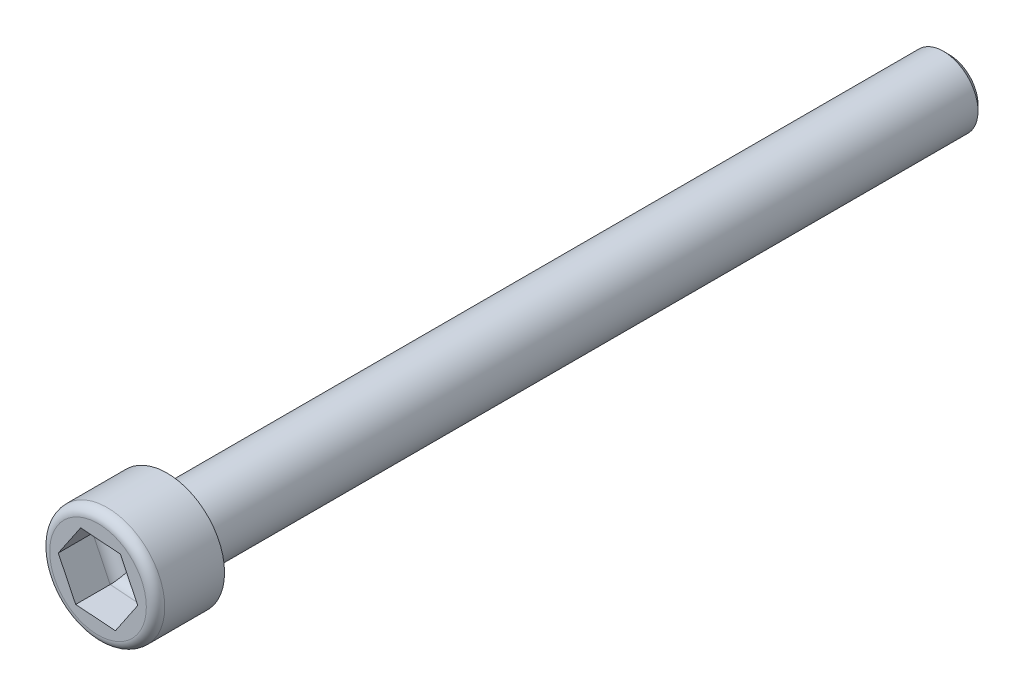
from build123d import *

# Parameters (mm, degrees)
SKETCH1_R           = 1.5
BOSS_EXTRUDE1_DEPTH = 34
SKETCH2_R           = 2.5
BOSS_EXTRUDE2_DEPTH = 3
CUT_EXTRUDE1_DEPTH  = 2
FILLET1_R           = 0.4
CHAMFER1_SIZE       = 0.25
FILLET2_R           = 0.5


with BuildPart() as part:
    # Sketch1 → Boss-Extrude1 (new body)
    with BuildSketch(Plane.XY):
        Circle(SKETCH1_R)
    extrude(amount=BOSS_EXTRUDE1_DEPTH)

    # Sketch2 → Boss-Extrude2 (add)
    with BuildSketch(Plane.XY.offset(34)):
        Circle(SKETCH2_R)
    extrude(amount=BOSS_EXTRUDE2_DEPTH)

    # Sketch3 → Cut-Extrude1 (cut)
    with BuildSketch(Plane.XY.offset(37)):
        Polygon((1.72759491, -0.124160484), (0.971323588, 1.434060838), (-0.756271322, 1.558221322), (-1.72759491, 0.124160484), (-0.971323588, -1.434060838), (0.756271322, -1.558221322), align=None)
    extrude(amount=-CUT_EXTRUDE1_DEPTH, mode=Mode.SUBTRACT)

    # Fillet1
    fillet1_edges = [part.edges().sort_by_distance(p)[0] for p in [
        (-2.5, 0, 37),
    ]]
    fillet(fillet1_edges, radius=FILLET1_R)

    # Chamfer1
    chamfer1_edges = [part.edges().sort_by_distance(p)[0] for p in [
        (-1.5, 0, 0),
    ]]
    chamfer(chamfer1_edges, length=CHAMFER1_SIZE)

    # Fillet2
    fillet2_edges = [part.edges().sort_by_distance(p)[0] for p in [
        (1.241933116, -0.841190903, 35),
        (-0.107526133, -1.49614108, 35),
        (-1.349459249, -0.654950177, 35),
        (-1.241933116, 0.841190903, 35),
        (0.107526133, 1.49614108, 35),
        (1.349459249, 0.654950177, 35),
    ]]
    fillet(fillet2_edges, radius=FILLET2_R)


solid = part.part
